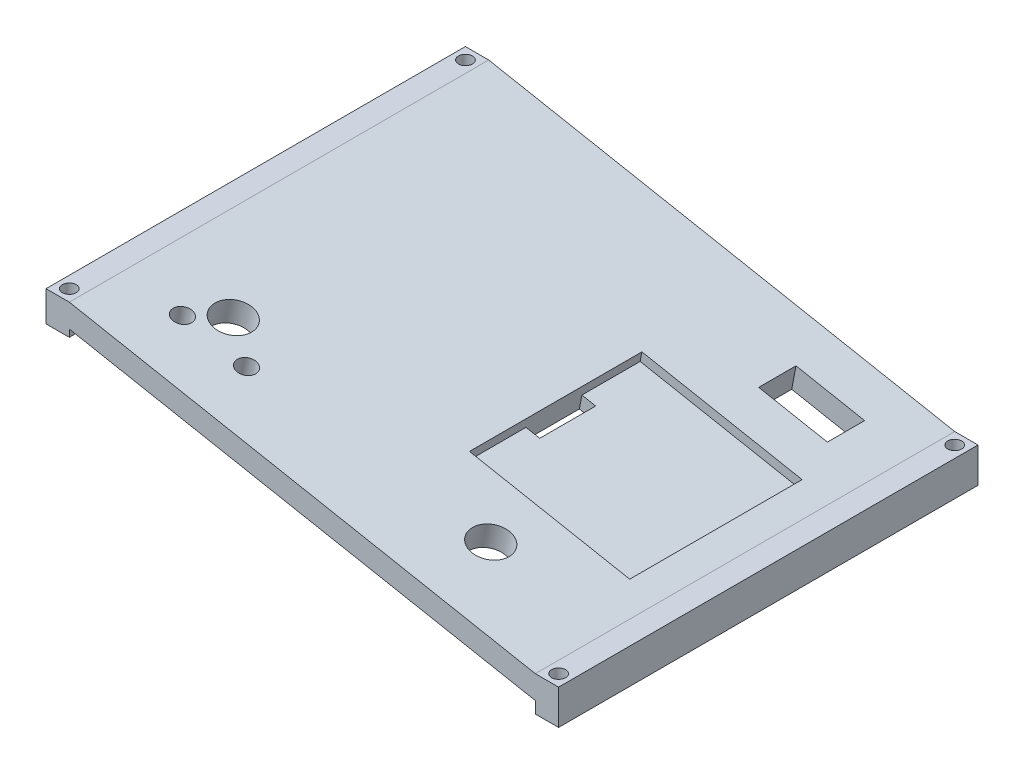
from build123d import *

# Parameters (mm, degrees)
SKETCH1_W           = 110
SKETCH1_H           = 90
BOSS_EXTRUDE2_DEPTH = 27.5
CUT_EXTRUDE5_DEPTH  = 90
SKETCH5_R           = 1.5
CUT_EXTRUDE7_DEPTH  = 7.5
SKETCH7_R           = 1.5
CUT_EXTRUDE9_DEPTH  = 7.5
SKETCH9_R           = 1.5
CUT_EXTRUDE11_DEPTH = 7.5
SKETCH12_R          = 1.5
CUT_EXTRUDE14_DEPTH = 7.5
CUT_EXTRUDE22_DEPTH = 2
SKETCH18_5_W        = 3
SKETCH18_5_H        = 12
CUT_EXTRUDE23_DEPTH = 5
SKETCH23_R          = 2
SKETCH23_R_2        = 4
CUT_EXTRUDE24_DEPTH = 5
SKETCH24_R          = 4
CUT_EXTRUDE25_DEPTH = 5
SKETCH25_W          = 15
SKETCH25_H          = 8
CUT_EXTRUDE26_DEPTH = 5


with BuildPart() as part:
    # Sketch1 → Boss-Extrude2 (new body)
    with BuildSketch(Plane(origin=(0, 0, 0), x_dir=(1, 0, 0), z_dir=(0, 1, 0))):
        Rectangle(SKETCH1_W, SKETCH1_H)
    extrude(amount=BOSS_EXTRUDE2_DEPTH)

    # Sketch4 → Cut-Extrude5 (cut)
    with BuildSketch(Plane.XY.offset(45)):
        Polygon((-55, 27.5), (-55, 26.547619048), (-50, 26.547619048), (50, 7.5), (55, 7.5), (55, 27.5), align=None)
        Polygon((50, 2.5), (-50, 21.547619048), (-50, 20), (-55, 20), (-55, 0), (50, 0), align=None)
    extrude(amount=-CUT_EXTRUDE5_DEPTH, mode=Mode.SUBTRACT)

    # Sketch5 → Cut-Extrude7 (cut)
    with BuildSketch(Plane(origin=(0, 7.5, 0), x_dir=(1, 0, 0), z_dir=(0, 1, 0))):
        with Locations((52.5, 42.5)):
            Circle(SKETCH5_R)
    extrude(amount=-CUT_EXTRUDE7_DEPTH, mode=Mode.SUBTRACT)

    # Sketch7 → Cut-Extrude9 (cut)
    with BuildSketch(Plane(origin=(0, 7.5, 0), x_dir=(1, 0, 0), z_dir=(0, 1, 0))):
        with Locations((52.5, -42.5)):
            Circle(SKETCH7_R)
    extrude(amount=-CUT_EXTRUDE9_DEPTH, mode=Mode.SUBTRACT)

    # Sketch9 → Cut-Extrude11 (cut)
    with BuildSketch(Plane(origin=(0, 26.547619048, 0), x_dir=(1, 0, 0), z_dir=(0, 1, 0))):
        with Locations((-52.5, 42.5)):
            Circle(SKETCH9_R)
    extrude(amount=-CUT_EXTRUDE11_DEPTH, mode=Mode.SUBTRACT)

    # Sketch12 → Cut-Extrude14 (cut)
    with BuildSketch(Plane(origin=(0, 26.547619048, 0), x_dir=(1, 0, 0), z_dir=(0, 1, 0))):
        with Locations((-52.5, -42.5)):
            Circle(SKETCH12_R)
    extrude(amount=-CUT_EXTRUDE14_DEPTH, mode=Mode.SUBTRACT)

    # Sketch18 → Cut-Extrude22 (cut)
    with BuildSketch(Plane(origin=(3.129102845, 16.427789934, 0), x_dir=(0.9823385664224747, -0.18711210788999524, 0), z_dir=(0.18711210788999524, 0.9823385664224747, 0))):
        Polygon((9.356793756, -6), (6.356793756, -6), (6.356793756, -18.5), (41.356793756, -18.5), (41.356793756, 18.5), (6.356793756, 18.5), (6.356793756, 6), (9.356793756, 6), align=None)
    extrude(amount=-CUT_EXTRUDE22_DEPTH, mode=Mode.SUBTRACT)

    # Sketch18_5 → Cut-Extrude23 (cut)
    with BuildSketch(Plane(origin=(3.129102845, 16.427789934, 0), x_dir=(0.9823385664224747, -0.18711210788999524, 0), z_dir=(0.18711210788999524, 0.9823385664224747, 0))):
        with Locations((7.856793756, 0)):
            Rectangle(SKETCH18_5_W, SKETCH18_5_H)
    extrude(amount=-CUT_EXTRUDE23_DEPTH, mode=Mode.SUBTRACT)

    # Sketch23 → Cut-Extrude24 (cut)
    with BuildSketch(Plane(origin=(3.129102845, 16.427789934, 0), x_dir=(0.9823385664224747, -0.18711210788999524, 0), z_dir=(0.18711210788999524, 0.9823385664224747, 0))):
        with Locations((-41.584309281, -33)):
            Circle(SKETCH23_R)
        with Locations((-27.584309281, -33)):
            Circle(SKETCH23_R)
        with Locations((-36.584309281, -27)):
            Circle(SKETCH23_R_2)
    extrude(amount=-CUT_EXTRUDE24_DEPTH, mode=Mode.SUBTRACT)

    # Sketch24 → Cut-Extrude25 (cut)
    with BuildSketch(Plane(origin=(3.129102845, 16.427789934, 0), x_dir=(0.9823385664224747, -0.18711210788999524, 0), z_dir=(0.18711210788999524, 0.9823385664224747, 0))):
        with Locations((22.713587512, -30)):
            Circle(SKETCH24_R)
    extrude(amount=-CUT_EXTRUDE25_DEPTH, mode=Mode.SUBTRACT)

    # Sketch25 → Cut-Extrude26 (cut)
    with BuildSketch(Plane(origin=(3.129102845, 16.427789934, 0), x_dir=(0.9823385664224747, -0.18711210788999524, 0), z_dir=(0.18711210788999524, 0.9823385664224747, 0))):
        with Locations((30.213587512, 31.5)):
            Rectangle(SKETCH25_W, SKETCH25_H)
    extrude(amount=-CUT_EXTRUDE26_DEPTH, mode=Mode.SUBTRACT)


solid = part.part
